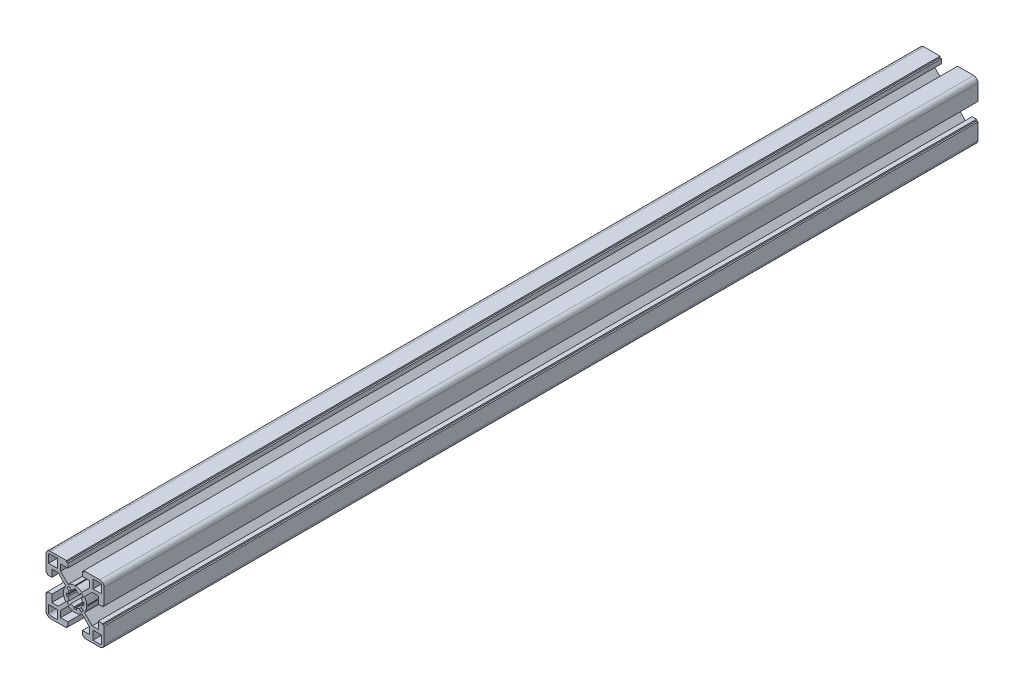
from build123d import *

# Parameters (mm, degrees)
BOSS_EXTRU_1_DEPTH = 600


with BuildPart() as part:
    # Esquisse1 → Boss.-Extru.1 (new body)
    with BuildSketch(Plane.XY.offset(100)):
        with BuildLine():
            Line((6, -19), (6, -20))
            Line((6, -20), (17, -20))
            ThreePointArc((17, -20), (19.121320344, -19.121320344), (20, -17))
            Line((20, -17), (20, -6))
            Line((20, -6), (19, -6))
            Line((19, -6), (19, -5))
            Line((19, -5), (16, -5))
            Line((16, -5), (16, -10))
            Line((16, -10), (11.697056276, -10))
            Line((11.697056276, -10), (6.44138072, -4.744324444))
            ThreePointArc((6.44138072, -4.744324444), (7.551143817, -2.642011933), (7.994130058, -0.306405969))
            Line((7.994130058, -0.306405969), (7.7, 0))
            Line((7.7, 0), (7.994130058, 0.306405971))
            ThreePointArc((7.994130058, 0.306405971), (7.551143817, 2.642011934), (6.441380719, 4.744324444))
            Line((6.441380719, 4.744324444), (11.697056275, 10))
            Line((11.697056275, 10), (16, 10))
            Line((16, 10), (16, 5))
            Line((16, 5), (19, 5))
            Line((19, 5), (19, 6))
            Line((19, 6), (20, 6))
            Line((20, 6), (20, 17))
            ThreePointArc((20, 17), (19.121320344, 19.121320344), (17, 20))
            Line((17, 20), (6, 20))
            Line((6, 20), (6, 19))
            Line((6, 19), (5, 19))
            Line((5, 19), (5, 15.999999999))
            Line((5, 15.999999999), (10.000000001, 15.999999999))
            Line((10.000000001, 15.999999999), (10.000000001, 11.697056275))
            Line((10.000000001, 11.697056275), (4.744324444, 6.441380719))
            ThreePointArc((4.744324444, 6.441380719), (2.642011933, 7.551143817), (0.306405969, 7.994130058))
            Line((0.306405969, 7.994130058), (0, 7.7))
            Line((0, 7.7), (-0.30640597, 7.994130058))
            ThreePointArc((-0.30640597, 7.994130058), (-2.642011933, 7.551143817), (-4.744324444, 6.441380719))
            Line((-4.744324444, 6.441380719), (-9.999999999, 11.697056274))
            Line((-9.999999999, 11.697056274), (-9.999999999, 15.999999999))
            Line((-9.999999999, 15.999999999), (-5, 15.999999999))
            Line((-5, 15.999999999), (-5, 19))
            Line((-5, 19), (-6, 19))
            Line((-6, 19), (-6, 20))
            Line((-6, 20), (-17, 20))
            ThreePointArc((-17, 20), (-19.121320344, 19.121320344), (-20, 17))
            Line((-20, 17), (-20, 6))
            Line((-20, 6), (-19, 6))
            Line((-19, 6), (-19, 5))
            Line((-19, 5), (-16, 5))
            Line((-16, 5), (-16, 10))
            Line((-16, 10), (-11.697056274, 10))
            Line((-11.697056274, 10), (-6.441380718, 4.744324445))
            ThreePointArc((-6.441380718, 4.744324445), (-7.551143817, 2.642011933), (-7.994130058, 0.306405969))
            Line((-7.994130058, 0.306405969), (-7.699999999, 0))
            Line((-7.699999999, 0), (-7.994130057, -0.306405971))
            ThreePointArc((-7.994130057, -0.306405971), (-7.551143816, -2.642011934), (-6.441380719, -4.744324444))
            Line((-6.441380719, -4.744324444), (-11.697056275, -10))
            Line((-11.697056275, -10), (-16, -10))
            Line((-16, -10), (-16, -5))
            Line((-16, -5), (-19, -5))
            Line((-19, -5), (-19, -6))
            Line((-19, -6), (-20, -6))
            Line((-20, -6), (-20, -17))
            ThreePointArc((-20, -17), (-19.121320344, -19.121320344), (-17, -20))
            Line((-17, -20), (-6, -20))
            Line((-6, -20), (-6, -19))
            Line((-6, -19), (-5, -19))
            Line((-5, -19), (-5, -16.000000001))
            Line((-5, -16.000000001), (-9.999999999, -16.000000001))
            Line((-9.999999999, -16.000000001), (-9.999999999, -11.697056274))
            Line((-9.999999999, -11.697056274), (-4.744324444, -6.441380719))
            ThreePointArc((-4.744324444, -6.441380719), (-2.642011933, -7.551143817), (-0.306405969, -7.994130058))
            Line((-0.306405969, -7.994130058), (0, -7.7))
            Line((0, -7.7), (0.306405971, -7.994130058))
            ThreePointArc((0.306405971, -7.994130058), (2.642011934, -7.551143817), (4.744324445, -6.441380719))
            Line((4.744324445, -6.441380719), (10.000000001, -11.697056274))
            Line((10.000000001, -11.697056274), (10.000000001, -16.000000001))
            Line((10.000000001, -16.000000001), (5, -16.000000001))
            Line((5, -16.000000001), (5, -19))
            Line((5, -19), (6, -19))
        make_face()
        with BuildLine():
            Line((18.25, 12.25), (12.25, 12.25))
            Line((12.25, 12.25), (12.25, 18.25))
            Line((12.25, 18.25), (17.25, 18.25))
            ThreePointArc((17.25, 18.25), (17.957106781, 17.957106781), (18.25, 17.25))
            Line((18.25, 17.25), (18.25, 12.25))
        make_face(mode=Mode.SUBTRACT)
        with BuildLine():
            Line((-18.25, -12.25), (-12.25, -12.25))
            Line((-12.25, -12.25), (-12.25, -18.25))
            Line((-12.25, -18.25), (-17.25, -18.25))
            ThreePointArc((-17.25, -18.25), (-17.957106781, -17.957106781), (-18.25, -17.25))
            Line((-18.25, -17.25), (-18.25, -12.25))
        make_face(mode=Mode.SUBTRACT)
        with BuildLine():
            Line((-12.25, 18.25), (-12.25, 12.25))
            Line((-12.25, 12.25), (-18.25, 12.25))
            Line((-18.25, 12.25), (-18.25, 17.25))
            ThreePointArc((-18.25, 17.25), (-17.957106781, 17.957106781), (-17.25, 18.25))
            Line((-17.25, 18.25), (-12.25, 18.25))
        make_face(mode=Mode.SUBTRACT)
        with BuildLine():
            Line((12.25, -18.25), (12.25, -12.25))
            Line((12.25, -12.25), (18.25, -12.25))
            Line((18.25, -12.25), (18.25, -17.25))
            ThreePointArc((18.25, -17.25), (17.957106781, -17.957106781), (17.25, -18.25))
            Line((17.25, -18.25), (12.25, -18.25))
        make_face(mode=Mode.SUBTRACT)
        with BuildLine():
            Line((-5.705709703, -4.055228326), (-4.075506937, -2.896591666))
            ThreePointArc((-4.075506937, -2.896591666), (-4.635549589, -1.873947727), (-4.943520622, -0.749402378))
            Line((-4.943520622, -0.749402378), (-5.932224738, -0.899282852))
            ThreePointArc((-5.932224738, -0.899282852), (-6, 0), (-5.932224738, 0.899282853))
            Line((-5.932224738, 0.899282853), (-4.943520622, 0.749402379))
            ThreePointArc((-4.943520622, 0.749402379), (-4.635549588, 1.873947727), (-4.075506937, 2.896591666))
            Line((-4.075506937, 2.896591666), (-5.705709704, 4.055228326))
            ThreePointArc((-5.705709704, 4.055228326), (-4.953610357, 4.945881563), (-4.064132573, 5.699370705))
            Line((-4.064132573, 5.699370705), (-2.902951842, 4.070979081))
            ThreePointArc((-2.902951842, 4.070979081), (-1.877566249, 4.634085136), (-0.749402377, 4.943520623))
            Line((-0.749402377, 4.943520623), (-0.899282852, 5.932224739))
            ThreePointArc((-0.899282852, 5.932224739), (0, 6), (0.899282852, 5.932224739))
            Line((0.899282852, 5.932224739), (0.749402377, 4.943520623))
            ThreePointArc((0.749402377, 4.943520623), (1.87756625, 4.634085136), (2.902951843, 4.07097908))
            Line((2.902951843, 4.07097908), (4.064132575, 5.699370704))
            ThreePointArc((4.064132575, 5.699370704), (4.953610358, 4.945881562), (5.705709704, 4.055228326))
            Line((5.705709704, 4.055228326), (4.075506937, 2.896591666))
            ThreePointArc((4.075506937, 2.896591666), (4.635549589, 1.873947727), (4.943520623, 0.749402378))
            Line((4.943520623, 0.749402378), (5.932224739, 0.899282853))
            ThreePointArc((5.932224739, 0.899282853), (6, 0), (5.932224739, -0.899282853))
            Line((5.932224739, -0.899282853), (4.943520623, -0.749402379))
            ThreePointArc((4.943520623, -0.749402379), (4.635549589, -1.873947727), (4.075506938, -2.896591666))
            Line((4.075506938, -2.896591666), (5.705709704, -4.055228326))
            ThreePointArc((5.705709704, -4.055228326), (4.953610357, -4.945881563), (4.064132573, -5.699370705))
            Line((4.064132573, -5.699370705), (2.902951842, -4.070979081))
            ThreePointArc((2.902951842, -4.070979081), (1.87756625, -4.634085136), (0.749402378, -4.943520623))
            Line((0.749402378, -4.943520623), (0.899282852, -5.932224739))
            ThreePointArc((0.899282852, -5.932224739), (1e-09, -6), (-0.899282851, -5.932224739))
            Line((-0.899282851, -5.932224739), (-0.749402377, -4.943520623))
            ThreePointArc((-0.749402377, -4.943520623), (-1.87756625, -4.634085136), (-2.902951843, -4.07097908))
            Line((-2.902951843, -4.07097908), (-4.064132574, -5.699370704))
            ThreePointArc((-4.064132574, -5.699370704), (-4.953610357, -4.945881562), (-5.705709703, -4.055228326))
        make_face(mode=Mode.SUBTRACT)
    extrude(amount=-BOSS_EXTRU_1_DEPTH)


solid = part.part
